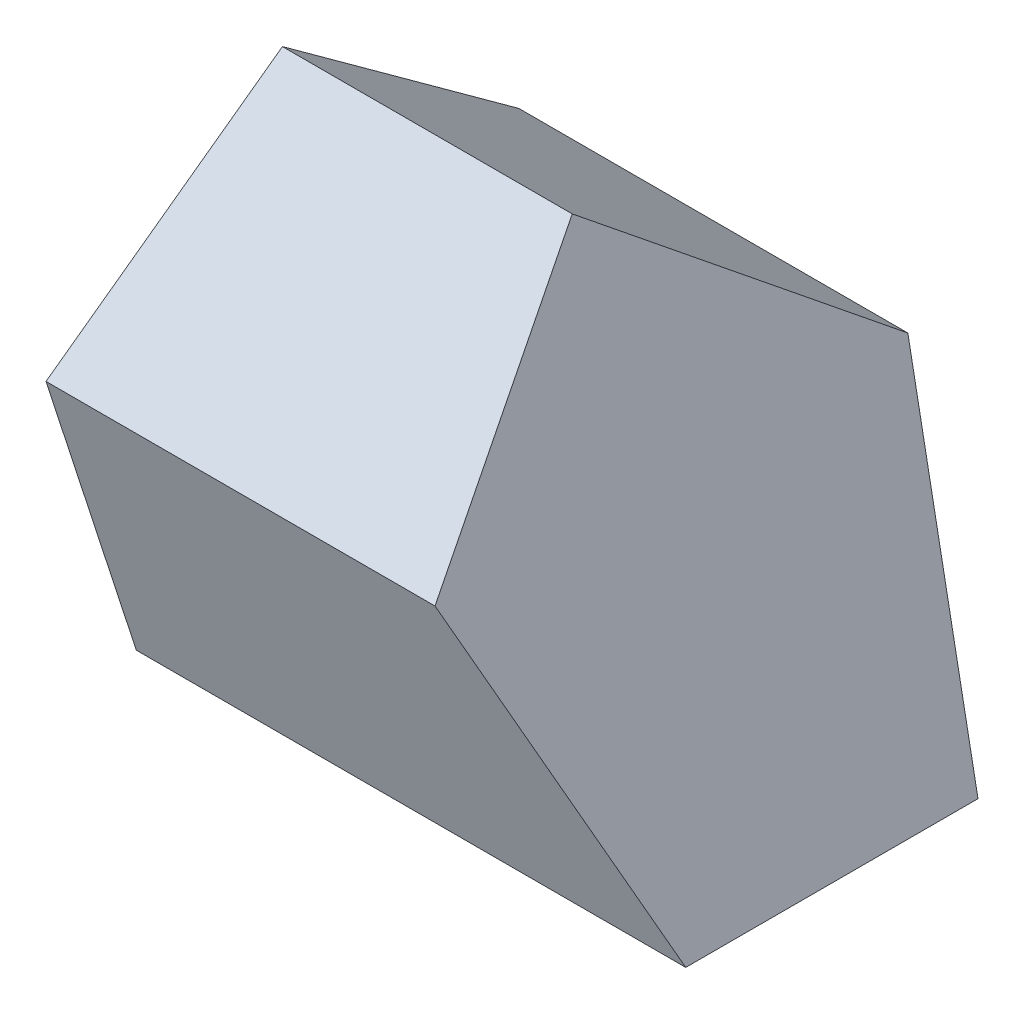
from build123d import *

# Parameters (mm, degrees)
EXTRUDE1_DEPTH     = 70
CUT_EXTRUDE1_DEPTH = 30


with BuildPart() as part:
    # Sketch1 → Extrude1 (new body)
    with BuildSketch(Plane(origin=(0, 0, 0), x_dir=(0, 0, -1), z_dir=(1, 0, 0))):
        Polygon((18.1635632, -25), (29.389262615, 9.549150281), (0, 30.901699437), (-29.389262615, 9.549150281), (-18.1635632, -25), align=None)
    extrude(amount=EXTRUDE1_DEPTH)

    # Sketch3 → Cut-Extrude1 (cut, symmetric)
    with BuildSketch(Plane.XY):
        Polygon((70, 30.901699437), (36.026408971, 30.901699437), (68.301270189, -25), (70, -25), align=None)
    extrude(amount=CUT_EXTRUDE1_DEPTH, both=True, mode=Mode.SUBTRACT)


with BuildPart() as body_2:
    # Sketch2 → Revolve1 (revolve)
    with BuildSketch(Plane.XY):
        with BuildLine():
            Line((25, -25), (25, 25))
            ThreePointArc((25, 25), (50, 0), (25, -25))
        make_face()
    revolve(axis=Axis((25, -25, 0), (0, 1, 0)))


solid = Compound([part.part, body_2.part])
